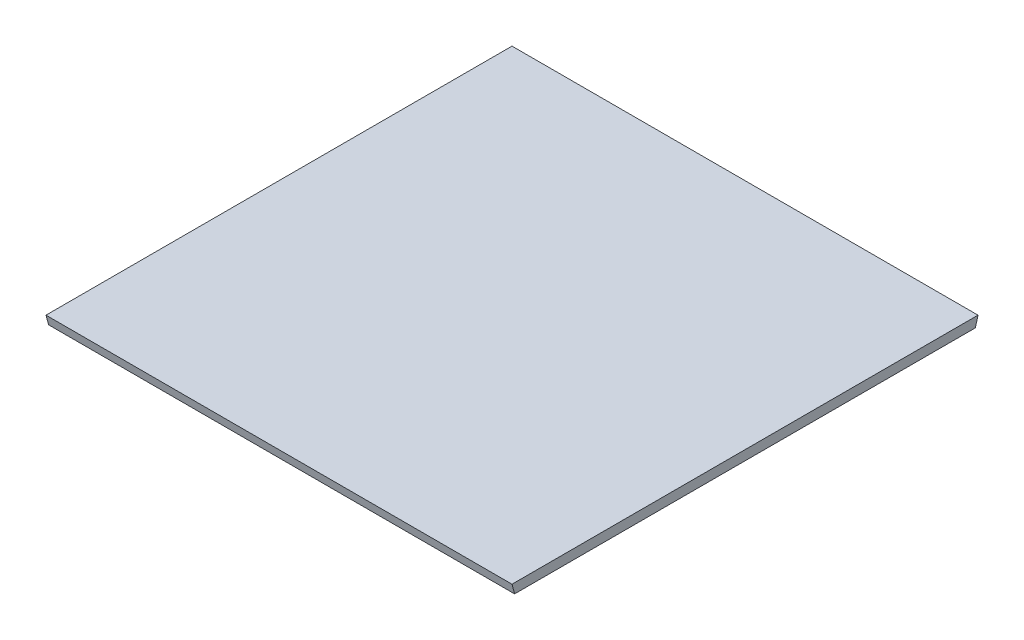
from build123d import *

# Parameters (mm, degrees)
BOSS_EXTRUDE1_DEPTH = 609.6


with BuildPart() as part:
    # Sketch1 → Boss-Extrude1 (new body)
    with BuildSketch(Plane(origin=(0, 0, 0), x_dir=(0, 0, -1), z_dir=(1, 0, 0))):
        Polygon((0, 0), (609.6, 0), (606.197045256, -12.7), (3.402954744, -12.7), align=None)
    extrude(amount=BOSS_EXTRUDE1_DEPTH)


solid = part.part
